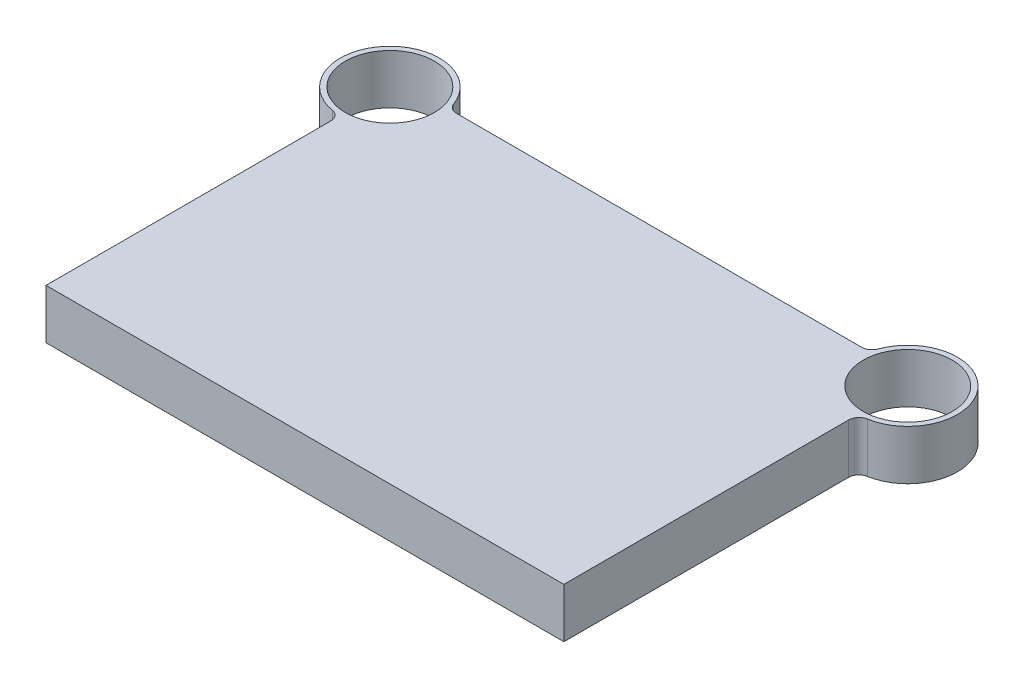
from build123d import *

# Parameters (mm, degrees)
SKETCH1_R           = 43
BOSS_EXTRUDE1_DEPTH = 48
FILLET1_R           = 10


with BuildPart() as part:
    # Sketch1 → Boss-Extrude1 (new body)
    with BuildSketch(Plane(origin=(0, 0, 0), x_dir=(1, 0, 0), z_dir=(0, 1, 0))):
        with BuildLine():
            Line((250, 0), (-250, 0))
            Line((-250, 0), (-250, 284))
            ThreePointArc((-250, 284), (-287.309516212, 362.199337741), (-203.053221623, 342))
            Line((-203.053221623, 342), (203.053221623, 342))
            ThreePointArc((203.053221623, 342), (287.309516212, 362.199337741), (250, 284))
            Line((250, 284), (250, 0))
        make_face()
        with Locations((-250, 332)):
            Circle(SKETCH1_R, mode=Mode.SUBTRACT)
        with Locations((250, 332)):
            Circle(SKETCH1_R, mode=Mode.SUBTRACT)
    extrude(amount=BOSS_EXTRUDE1_DEPTH)

    # Fillet1
    fillet1_edges = [part.edges().sort_by_distance(p)[0] for p in [
        (-250, 24, -284),
        (-203.053221623, 24, -342),
        (203.053221623, 24, -342),
        (250, 24, -284),
    ]]
    fillet(fillet1_edges, radius=FILLET1_R)


solid = part.part
